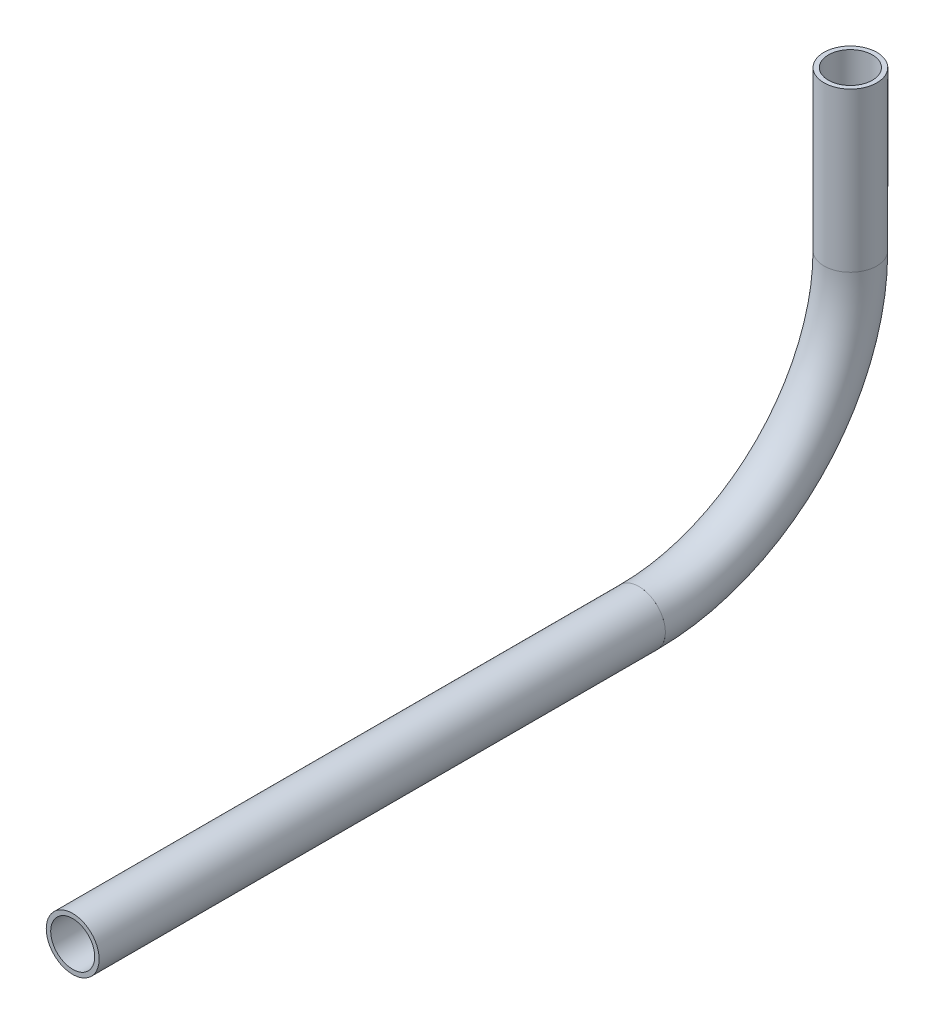
from build123d import *

# Parameters (mm, degrees)
SKETCH11_R                = 6.35
SKETCH11_R_2              = 5.2832
PIPE_0_5_SCH_40_1_DEPTH   = 136.005637638
SKETCH11_ON_SEGMENT_2_R   = 6.35
SKETCH11_ON_SEGMENT_2_R_2 = 5.2832
PIPE_0_5_SCH_40_1_2_ANGLE = 90
SKETCH11_ON_SEGMENT_3_R   = 6.35
SKETCH11_ON_SEGMENT_3_R_2 = 5.2832
PIPE_0_5_SCH_40_1_3_DEPTH = 38.1


with BuildPart() as part:
    # Sketch11 → Pipe 0.5 SCH 40(1) (new body)
    with BuildSketch(Plane(origin=(0, 599.960019272, 303.164595711), x_dir=(0, 1, 0), z_dir=(0, 0, -1))):
        Circle(SKETCH11_R)
        Circle(SKETCH11_R_2, mode=Mode.SUBTRACT)
    extrude(amount=PIPE_0_5_SCH_40_1_DEPTH)


with BuildPart() as body_2:
    # Sketch11 on segment 2 (carried to the start of arc 2) → Pipe 0.5 SCH 40_1 2 (revolve)
    with BuildSketch(Plane(origin=(0, 599.960019272, 167.158958073), x_dir=(0, 1, 0), z_dir=(0, 0, -1))):
        Circle(SKETCH11_ON_SEGMENT_2_R)
        Circle(SKETCH11_ON_SEGMENT_2_R_2, mode=Mode.SUBTRACT)
    revolve(axis=Axis((0, 650.760019272, 167.158958073), (1, 0, 0)), revolution_arc=PIPE_0_5_SCH_40_1_2_ANGLE)


with BuildPart() as body_3:
    # Sketch11 on segment 3 (carried to segment 3) → Pipe 0.5 SCH 40_1 3 (new body)
    with BuildSketch(Plane(origin=(0, 650.760019272, 116.358958073), x_dir=(0, 0, 1), z_dir=(0, 1, 0))):
        Circle(SKETCH11_ON_SEGMENT_3_R)
        Circle(SKETCH11_ON_SEGMENT_3_R_2, mode=Mode.SUBTRACT)
    extrude(amount=PIPE_0_5_SCH_40_1_3_DEPTH)


solid = Compound([part.part, body_2.part, body_3.part])
